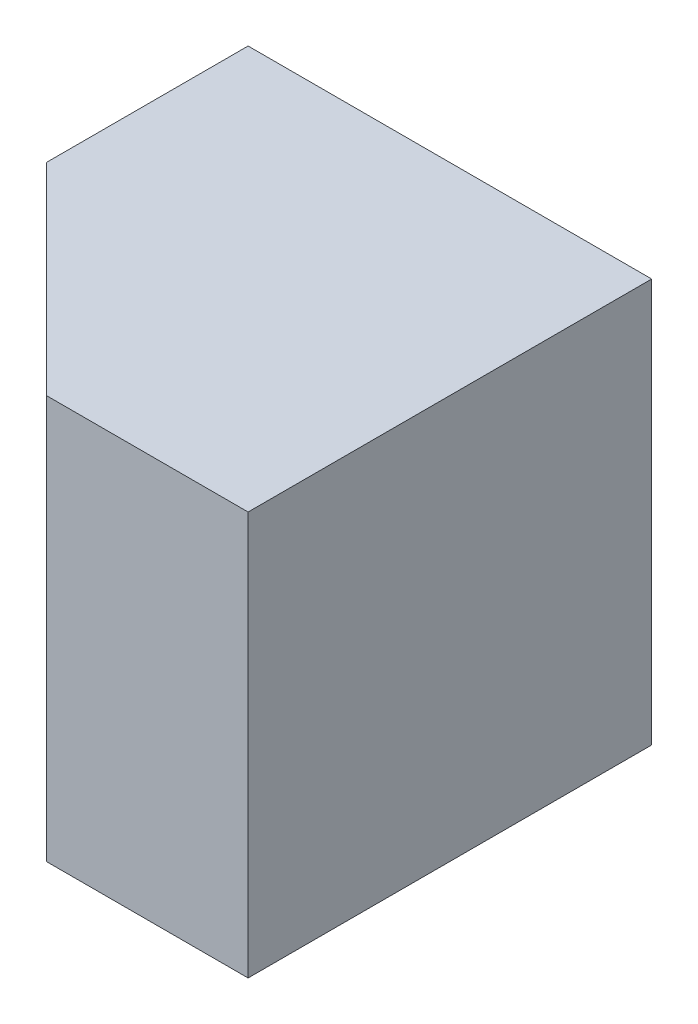
from build123d import *

# Parameters (mm, degrees)
SKETCH1_W           = 20
SKETCH1_H           = 20
BOSS_EXTRUDE1_DEPTH = 20
CUT_EXTRUDE1_DEPTH  = 20


with BuildPart() as part:
    # Sketch1 → Boss-Extrude1 (new body)
    with BuildSketch(Plane.XY):
        with Locations((10, 10)):
            Rectangle(SKETCH1_W, SKETCH1_H)
    extrude(amount=BOSS_EXTRUDE1_DEPTH)

    # Sketch2 → Cut-Extrude1 (cut)
    with BuildSketch(Plane(origin=(0, 20, 0), x_dir=(1, 0, 0), z_dir=(0, 1, 0))):
        Polygon((0, -10), (10, -20), (0, -20), align=None)
    extrude(amount=-CUT_EXTRUDE1_DEPTH, mode=Mode.SUBTRACT)


solid = part.part
